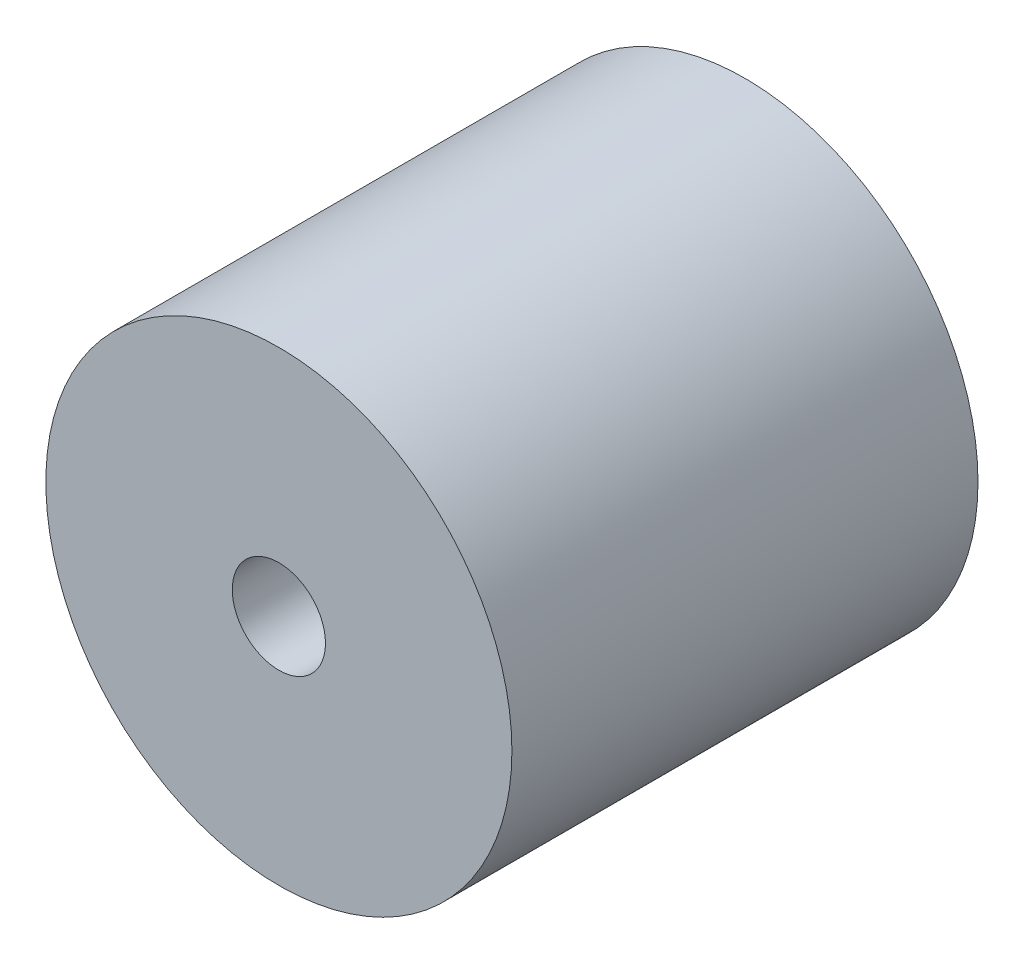
from build123d import *

# Parameters (mm, degrees)
CROQUIS1_R              = 0.5
CROQUIS1_R_2            = 0.1
SALIENTE_EXTRUIR1_DEPTH = 1


with BuildPart() as part:
    # Croquis1 → Saliente-Extruir1 (new body)
    with BuildSketch(Plane.XY):
        Circle(CROQUIS1_R)
        Circle(CROQUIS1_R_2, mode=Mode.SUBTRACT)
    extrude(amount=SALIENTE_EXTRUIR1_DEPTH)


solid = part.part
